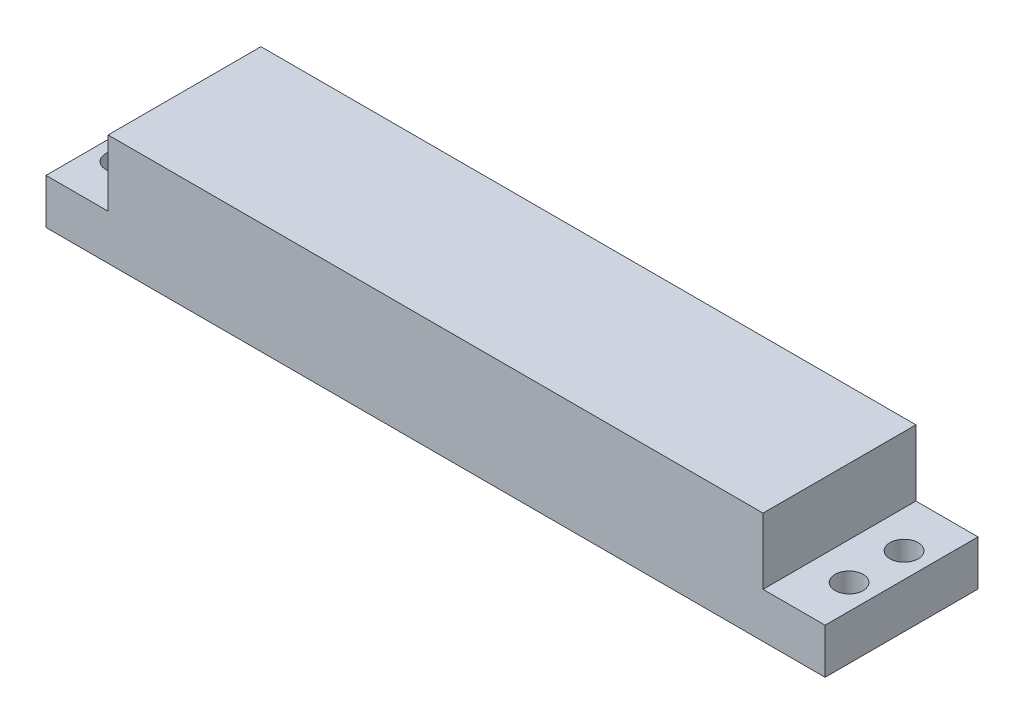
from build123d import *

# Parameters (mm, degrees)
SKETCH1_W           = 112.1
SKETCH1_H           = 22
SKETCH1_R           = 2.025
BOSS_EXTRUDE1_DEPTH = 6.5
SKETCH2_W           = 94.239862036
SKETCH2_H           = 22
BOSS_EXTRUDE3_DEPTH = 9.5


with BuildPart() as part:
    # Sketch1 → Boss-Extrude1 (new body)
    with BuildSketch(Plane(origin=(0, 0, 0), x_dir=(1, 0, 0), z_dir=(0, 1, 0))):
        Rectangle(SKETCH1_W, SKETCH1_H)
        with Locations((-52.455, 3.955)):
            Circle(SKETCH1_R, mode=Mode.SUBTRACT)
        with Locations((-52.455, -3.955)):
            Circle(SKETCH1_R, mode=Mode.SUBTRACT)
        with Locations((52.455, -3.955)):
            Circle(SKETCH1_R, mode=Mode.SUBTRACT)
        with Locations((52.455, 3.955)):
            Circle(SKETCH1_R, mode=Mode.SUBTRACT)
    extrude(amount=BOSS_EXTRUDE1_DEPTH)

    # Sketch2 → Boss-Extrude3 (add)
    with BuildSketch(Plane(origin=(0, 6.5, 0), x_dir=(1, 0, 0), z_dir=(0, 1, 0))):
        Rectangle(SKETCH2_W, SKETCH2_H)
    extrude(amount=BOSS_EXTRUDE3_DEPTH)


solid = part.part
